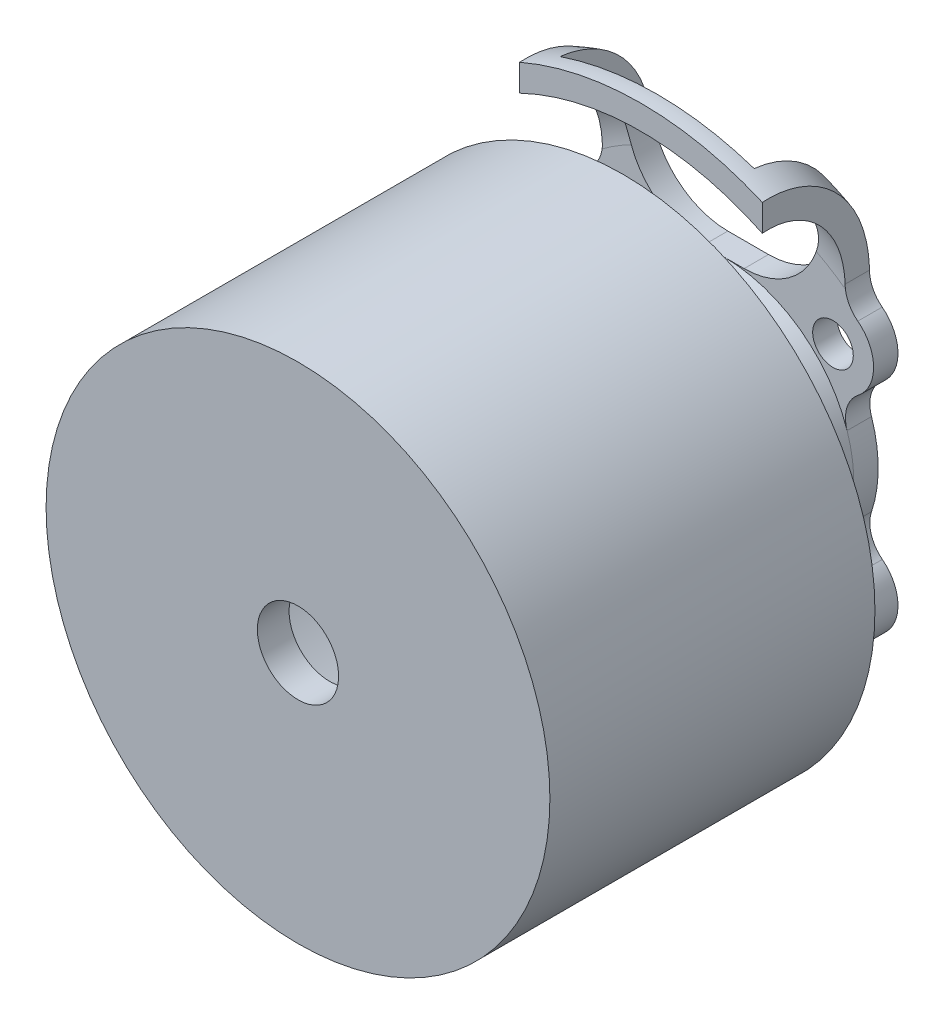
from build123d import *

# Parameters (mm, degrees)
SKETCH2_R          = 1.25
CUT_EXTRUDE1_DEPTH = 5.599304
CUT_EXTRUDE2_REACH = 8.599


with BuildPart() as part:
    # Sketch1 → Revolve1 (revolve)
    with BuildSketch(Plane(origin=(0, 0, 0), x_dir=(0, 0, -1), z_dir=(1, 0, 0))):
        with BuildLine():
            Line((0, 15.5), (20, 15.5))
            Line((20, 15.5), (20, 6.5))
            Line((20, 6.5), (26.2, 8))
            Line((26.2, 8), (26.2, 12.5))
            ThreePointArc((26.2, 12.5), (24.683117, 15.981117), (21.100696, 17.240231))
            Line((21.100696, 17.240231), (21.100696, 18.740231))
            ThreePointArc((21.100696, 18.740231), (25.744144, 17.041236), (27.7, 12.5))
            Line((27.7, 12.5), (27.7, 2.5))
            Line((27.7, 2.5), (20, 2.5))
            Line((20, 2.5), (18.05, 2.5))
            Line((18.05, 2.5), (18.05, 13.5))
            Line((18.05, 13.5), (1.95, 13.5))
            Line((1.95, 13.5), (1.95, 2.5))
            Line((1.95, 2.5), (0, 2.5))
            Line((0, 2.5), (0, 15.5))
        make_face()
    revolve(axis=Axis((0, 0, -20), (0, 0, 1)))

    # Sketch2 → Cut-Extrude1 (cut)
    with BuildSketch(Plane(origin=(0, 0, -27.7), x_dir=(-1, 0, 0), z_dir=(0, 0, -1))):
        with Locations((-6.717514, 6.717514)):
            Circle(SKETCH2_R)
        with Locations((6.717514, 6.717514)):
            Circle(SKETCH2_R)
        with Locations((6.717514, -6.717514)):
            Circle(SKETCH2_R)
        with Locations((-6.717514, -6.717514)):
            Circle(SKETCH2_R)
        with BuildLine():
            Line((-5.967514, 23.416114), (-5.967514, 12.717514))
            ThreePointArc((-5.967514, 12.717514), (-4.585786, 9.381728), (-1.25, 8))
            Line((-1.25, 8), (1.25, 8))
            ThreePointArc((1.25, 8), (4.585786, 9.381728), (5.967514, 12.717514))
            Line((5.967514, 12.717514), (5.967514, 23.416114))
            Line((5.967514, 23.416114), (-5.967514, 23.416114))
        make_face()
        with BuildLine():
            Line((-7.467514, 23.416114), (-7.467514, 10.279466))
            ThreePointArc((-7.467514, 10.279466), (-7.672459, 9.397549), (-8.245292, 8.696376))
            ThreePointArc((-8.245292, 8.696376), (-9.217507, 6.723535), (-8.254806, 4.746034))
            ThreePointArc((-8.254806, 4.746034), (-7.569897, 3.746571), (-7.587712, 2.53508))
            ThreePointArc((-7.587712, 2.53508), (-8, 0), (-7.587712, -2.53508))
            ThreePointArc((-7.587712, -2.53508), (-7.569897, -3.746571), (-8.254806, -4.746034))
            ThreePointArc((-8.254806, -4.746034), (-8.485281, -8.485281), (-4.746034, -8.254806))
            ThreePointArc((-4.746034, -8.254806), (-3.746571, -7.569897), (-2.53508, -7.587712))
            ThreePointArc((-2.53508, -7.587712), (0, -8), (2.53508, -7.587712))
            ThreePointArc((2.53508, -7.587712), (3.746571, -7.569897), (4.746034, -8.254806))
            ThreePointArc((4.746034, -8.254806), (8.485281, -8.485281), (8.254806, -4.746034))
            ThreePointArc((8.254806, -4.746034), (7.569897, -3.746571), (7.587712, -2.53508))
            ThreePointArc((7.587712, -2.53508), (8, 0), (7.587712, 2.53508))
            ThreePointArc((7.587712, 2.53508), (7.569897, 3.746571), (8.254806, 4.746034))
            ThreePointArc((8.254806, 4.746034), (9.217507, 6.723535), (8.245292, 8.696376))
            ThreePointArc((8.245292, 8.696376), (7.672459, 9.397549), (7.467514, 10.279466))
            Line((7.467514, 10.279466), (7.467514, 23.416114))
            ThreePointArc((7.467514, 23.416114), (0, -26.279016), (-7.467514, 23.416114))
        make_face()
    extrude(amount=-CUT_EXTRUDE1_DEPTH, mode=Mode.SUBTRACT)

    # Sketch3 → Cut-Extrude2 (cut, up to next)
    with BuildSketch(Plane.XY.offset(-21.100696), mode=Mode.PRIVATE) as cut_extrude2_sk1:
        with BuildLine():
            Line((7.467514, 17.1988), (7.467514, 15.502966))
            ThreePointArc((7.467514, 15.502966), (0, -17.207723), (-7.467514, 15.502966))
            Line((-7.467514, 15.502966), (-7.467514, 17.1988))
            ThreePointArc((-7.467514, 17.1988), (0, -18.75), (7.467514, 17.1988))
        make_face()
    cut_extrude2_tool1 = extrude(cut_extrude2_sk1.sketch, amount=-CUT_EXTRUDE2_REACH, mode=Mode.PRIVATE) & part.part
    add(cut_extrude2_tool1.solids().sort_by_distance((7.986992, 16.350883, -21.100696))[0], mode=Mode.SUBTRACT)


solid = part.part
